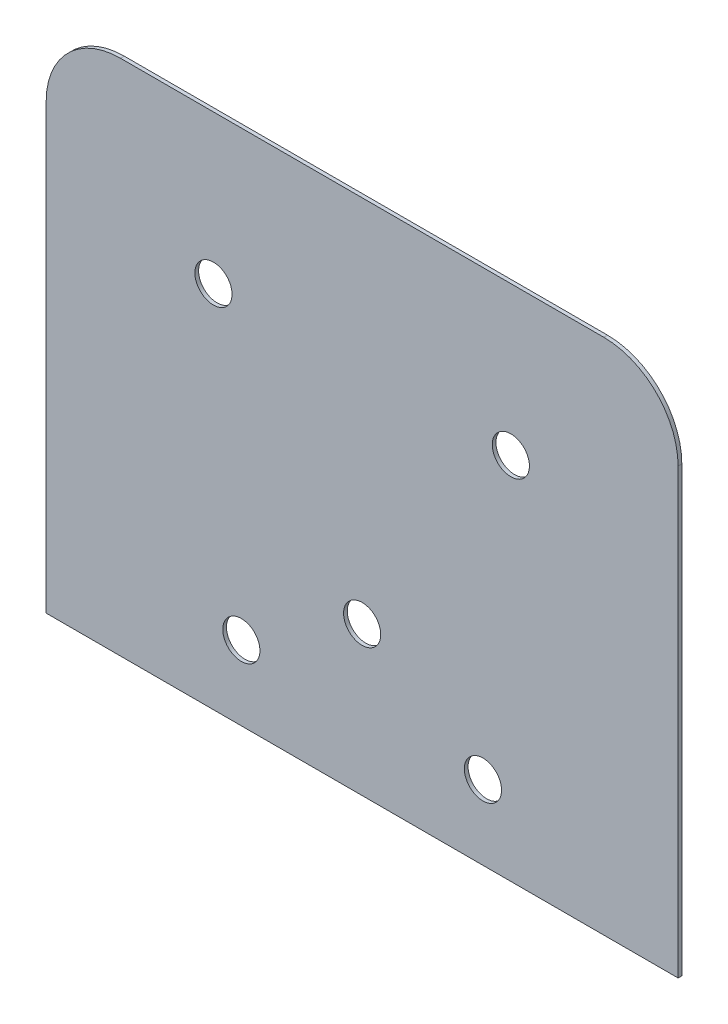
from build123d import *

# Parameters (mm, degrees)
ESBO_O1_R                = 5
RESSALTO_EXTRUS_O1_DEPTH = 1


with BuildPart() as part:
    # Esboço1 → Ressalto-extrusão1 (new body)
    with BuildSketch(Plane.XY):
        with BuildLine():
            Line((-87.5, 318.171952776), (-120, 318.171952776))
            Line((-120, 318.171952776), (-152.5, 318.171952776))
            Line((-152.5, 318.171952776), (-185, 318.171952776))
            ThreePointArc((-185, 318.171952776), (-199.142135624, 312.3140884), (-205, 298.171952776))
            Line((-205, 298.171952776), (-205, 178.888220282))
            Line((-205, 178.888220282), (-35, 178.888220282))
            Line((-35, 178.888220282), (-35, 298.171952776))
            ThreePointArc((-35, 298.171952776), (-40.857864376, 312.3140884), (-55, 318.171952776))
            Line((-55, 318.171952776), (-87.5, 318.171952776))
        make_face()
        with Locations((-152.5, 198.888220282)):
            Circle(ESBO_O1_R, mode=Mode.SUBTRACT)
        with Locations((-87.5, 198.888220282)):
            Circle(ESBO_O1_R, mode=Mode.SUBTRACT)
        with Locations((-120, 218.888220282)):
            Circle(ESBO_O1_R, mode=Mode.SUBTRACT)
        with Locations((-160, 278.171952776)):
            Circle(ESBO_O1_R, mode=Mode.SUBTRACT)
        with Locations((-80, 278.171952776)):
            Circle(ESBO_O1_R, mode=Mode.SUBTRACT)
    extrude(amount=RESSALTO_EXTRUS_O1_DEPTH)


solid = part.part
